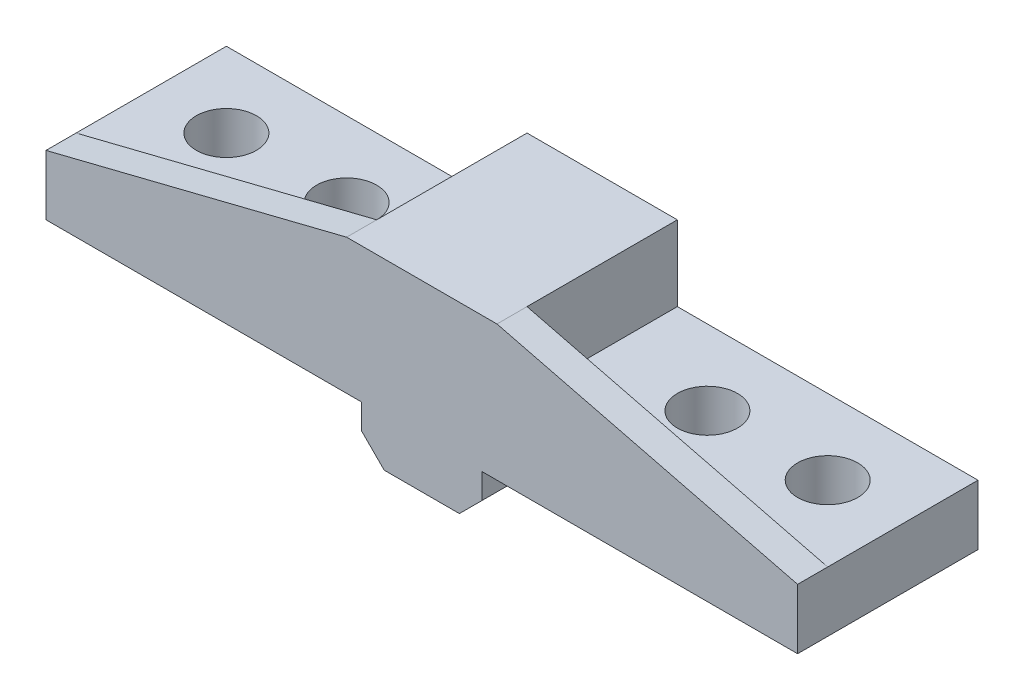
from build123d import *

# Parameters (mm, degrees)
BOSS_EXTRUDE1_DEPTH = 10
BOSS_EXTRUDE2_DEPTH = 2
SKETCH3_R           = 2
CUT_EXTRUDE1_DEPTH  = 4
CHAMFER1_SIZE       = 1.5


with BuildPart() as part:
    # Sketch1 → Boss-Extrude1 (new body)
    with BuildSketch(Plane.XY):
        Polygon((-25, 3.175), (-25, 7.175), (-5, 7.175), (-5, 12.175), (5, 12.175), (5, 7.175), (25, 7.175), (25, 3.175), (4, 3.175), (4, 0), (-4, 0), (-4, 3.175), align=None)
    extrude(amount=BOSS_EXTRUDE1_DEPTH)

    # Sketch2 → Boss-Extrude2 (add)
    with BuildSketch(Plane.XY.offset(10)):
        Polygon((-5, 12.175), (-25, 7.175), (-25, 3.175), (-4, 3.175), (-4, 0), (4, 0), (4, 3.175), (25, 3.175), (25, 7.175), (5, 12.175), align=None)
    extrude(amount=BOSS_EXTRUDE2_DEPTH)

    # Sketch3 → Cut-Extrude1 (cut)
    with BuildSketch(Plane(origin=(0, 7.175, 0), x_dir=(1, 0, 0), z_dir=(0, 1, 0))):
        with Locations((12, -5)):
            Circle(SKETCH3_R)
        with Locations((20, -5)):
            Circle(SKETCH3_R)
        with Locations((-12, -5)):
            Circle(SKETCH3_R)
        with Locations((-20, -5)):
            Circle(SKETCH3_R)
    extrude(amount=-CUT_EXTRUDE1_DEPTH, mode=Mode.SUBTRACT)

    # Chamfer1
    chamfer1_edges = [part.edges().sort_by_distance(p)[0] for p in [
        (4, 0, 6),
        (-4, 0, 6),
    ]]
    chamfer(chamfer1_edges, length=CHAMFER1_SIZE)


solid = part.part
